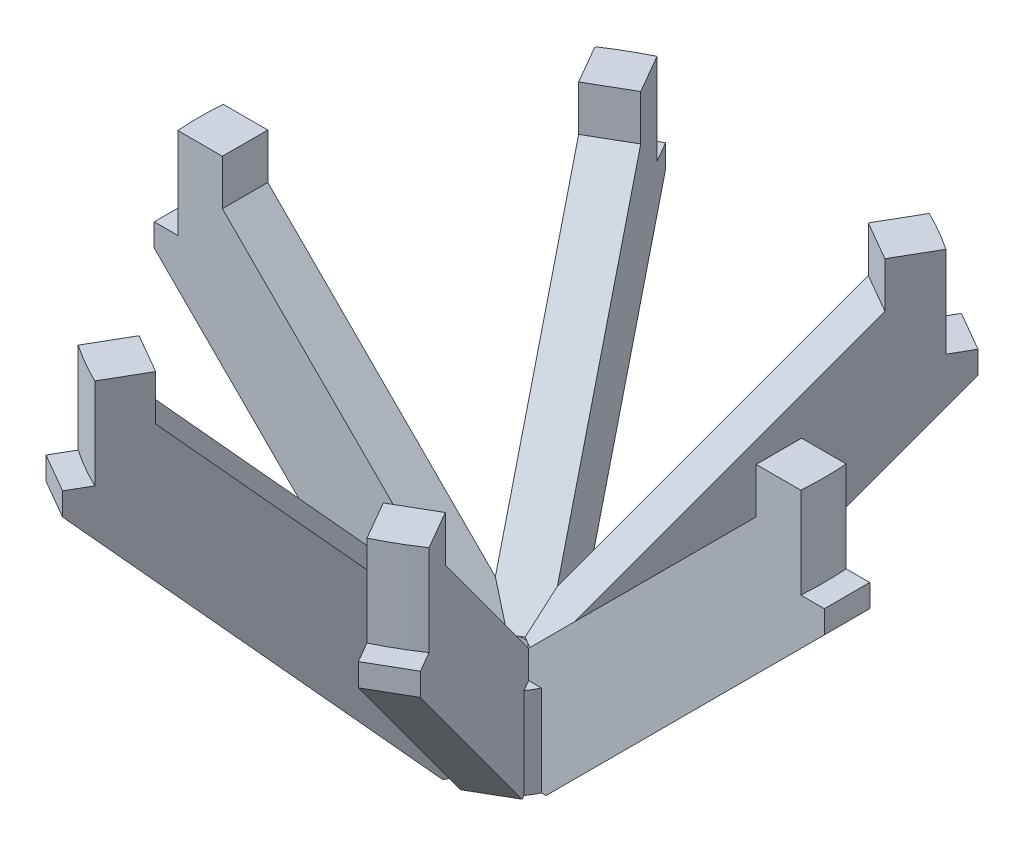
from build123d import *

# Parameters (mm, degrees)
SKETCH1_R           = 4
SKETCH1_R_2         = 0.8
BOSS_EXTRUDE1_DEPTH = 6.4
BOSS_EXTRUDE2_DEPTH = 1.6
CIRPATTERN1_COUNT   = 6
SKETCH3_R           = 23.654175107
SKETCH3_R_2         = 22
CUT_EXTRUDE1_DEPTH  = 6.4


with BuildPart() as part:
    # Sketch1 → Boss-Extrude1 (new body)
    with BuildSketch(Plane(origin=(0, 0, 0), x_dir=(1, 0, 0), z_dir=(0, 1, 0))):
        Circle(SKETCH1_R)
        Circle(SKETCH1_R_2, mode=Mode.SUBTRACT)
    extrude(amount=BOSS_EXTRUDE1_DEPTH)

    # Sketch2 → Boss-Extrude2 (add, symmetric)
    with BuildSketch(Plane.XY):
        Polygon((-4, 0), (-23.6, 19.6), (-23.6, 21.2), (-22, 21.2), (-22, 27.6), (-18.8, 27.6), (-18.8, 24.4), (-0.8, 6.4), (-0.8, 0), align=None)
    boss_extrude2 = extrude(amount=BOSS_EXTRUDE2_DEPTH, both=True)

    # CirPattern1: Boss-Extrude2 ×6 about axis
    cirpattern1_axis = Axis((0, 0, 0), (0, 1, 0))
    for i in range(1, CIRPATTERN1_COUNT):
        add(boss_extrude2.rotate(cirpattern1_axis, i * 360 / CIRPATTERN1_COUNT))

    # Sketch3 → Cut-Extrude1 (cut)
    with BuildSketch(Plane(origin=(0, 27.6, 0), x_dir=(1, 0, 0), z_dir=(0, 1, 0))):
        Circle(SKETCH3_R)
        Circle(SKETCH3_R_2, mode=Mode.SUBTRACT)
    extrude(amount=-CUT_EXTRUDE1_DEPTH, mode=Mode.SUBTRACT)


solid = part.part
